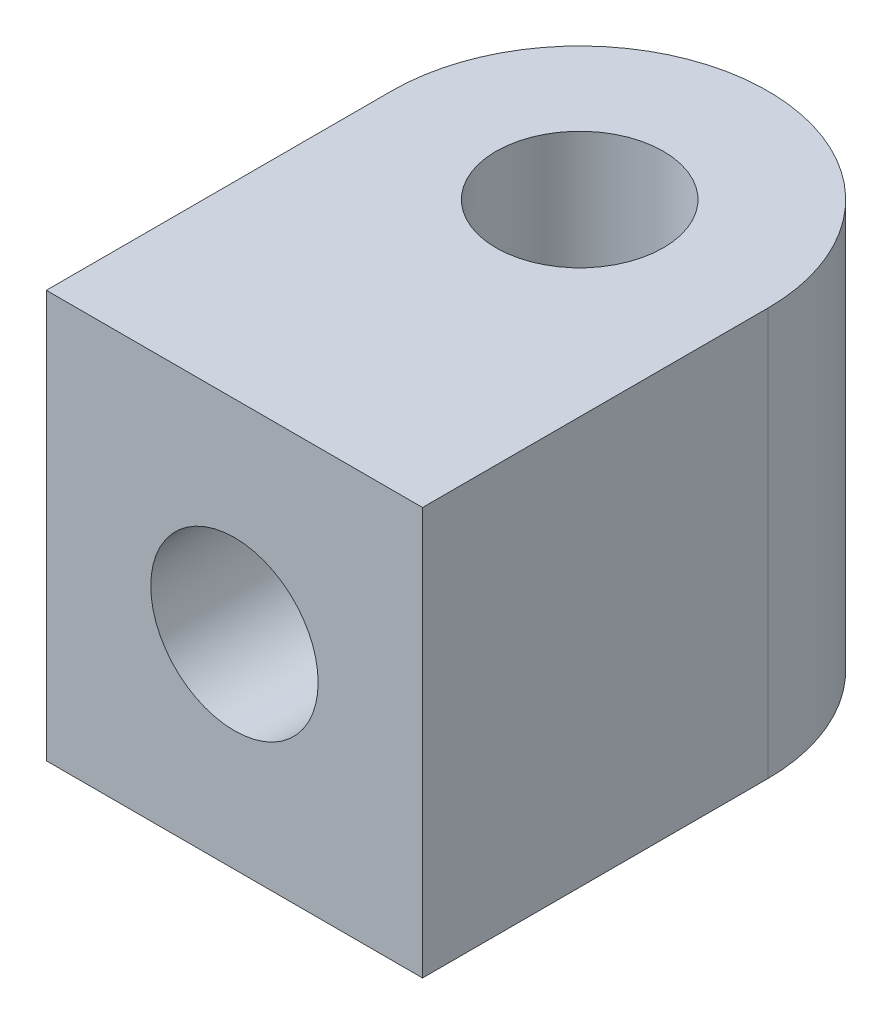
from build123d import *

# Parameters (mm, degrees)
BOSS_EXTRUDE1_DEPTH         = 6.58622
M2_5_CLEARANCE_HOLE1_D      = 2.7051
M2_5_CLEARANCE_HOLE2_REACH  = 13.267
M2_5_CLEARANCE_HOLE2_BORE_R = 1.35255


with BuildPart() as part:
    # Sketch1 → Boss-Extrude1 (new body)
    with BuildSketch(Plane.XZ):
        with BuildLine():
            Line((3.04038, 0), (3.04038, 5.58038))
            Line((3.04038, 5.58038), (-3.04038, 5.58038))
            Line((-3.04038, 5.58038), (-3.04038, 0))
            ThreePointArc((-3.04038, 0), (0, -3.04038), (3.04038, 0))
        make_face()
    extrude(amount=-BOSS_EXTRUDE1_DEPTH)

    # M2.5 Clearance Hole1 (through all)
    with Locations(Plane(origin=(0, 0, 0), x_dir=(-1, 0, 0), z_dir=(0, -1, 0))):
        with Locations((0, 0)):
            Hole(M2_5_CLEARANCE_HOLE1_D / 2)

    # M2.5 Clearance Hole2 bore → M2.5 Clearance Hole2 (cut, up to next)
    with BuildSketch(Plane.XY.offset(5.58038), mode=Mode.PRIVATE) as m2_5_clearance_hole2_sk1:
        with Locations((0, 3.29311)):
            Circle(M2_5_CLEARANCE_HOLE2_BORE_R)
    m2_5_clearance_hole2_tool1 = extrude(m2_5_clearance_hole2_sk1.sketch, amount=-M2_5_CLEARANCE_HOLE2_REACH, mode=Mode.PRIVATE) & part.part
    add(m2_5_clearance_hole2_tool1.solids().sort_by_distance((0, 3.29311, 5.58038))[0], mode=Mode.SUBTRACT)


solid = part.part
